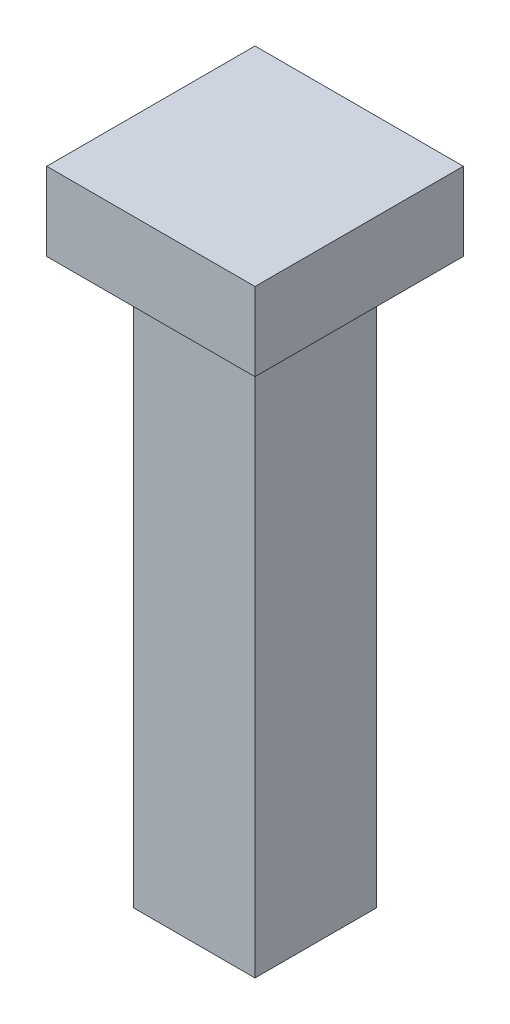
from build123d import *

# Parameters (mm, degrees)
SKETCH1_W           = 3.556
SKETCH1_H           = 3.556
BOSS_EXTRUDE1_DEPTH = 16.51
SKETCH2_W           = 6.096
SKETCH2_H           = 6.096
BOSS_EXTRUDE2_DEPTH = 2.286


with BuildPart() as part:
    # Sketch1 → Boss-Extrude1 (new body)
    with BuildSketch(Plane(origin=(0, 0, 0), x_dir=(1, 0, 0), z_dir=(0, 1, 0))):
        with Locations((1.778, -1.778)):
            Rectangle(SKETCH1_W, SKETCH1_H)
    extrude(amount=BOSS_EXTRUDE1_DEPTH)

    # Sketch2 → Boss-Extrude2 (add)
    with BuildSketch(Plane(origin=(0, 16.51, 0), x_dir=(1, 0, 0), z_dir=(0, 1, 0))):
        with Locations((1.778, -1.778)):
            Rectangle(SKETCH2_W, SKETCH2_H)
    extrude(amount=BOSS_EXTRUDE2_DEPTH)


solid = part.part
